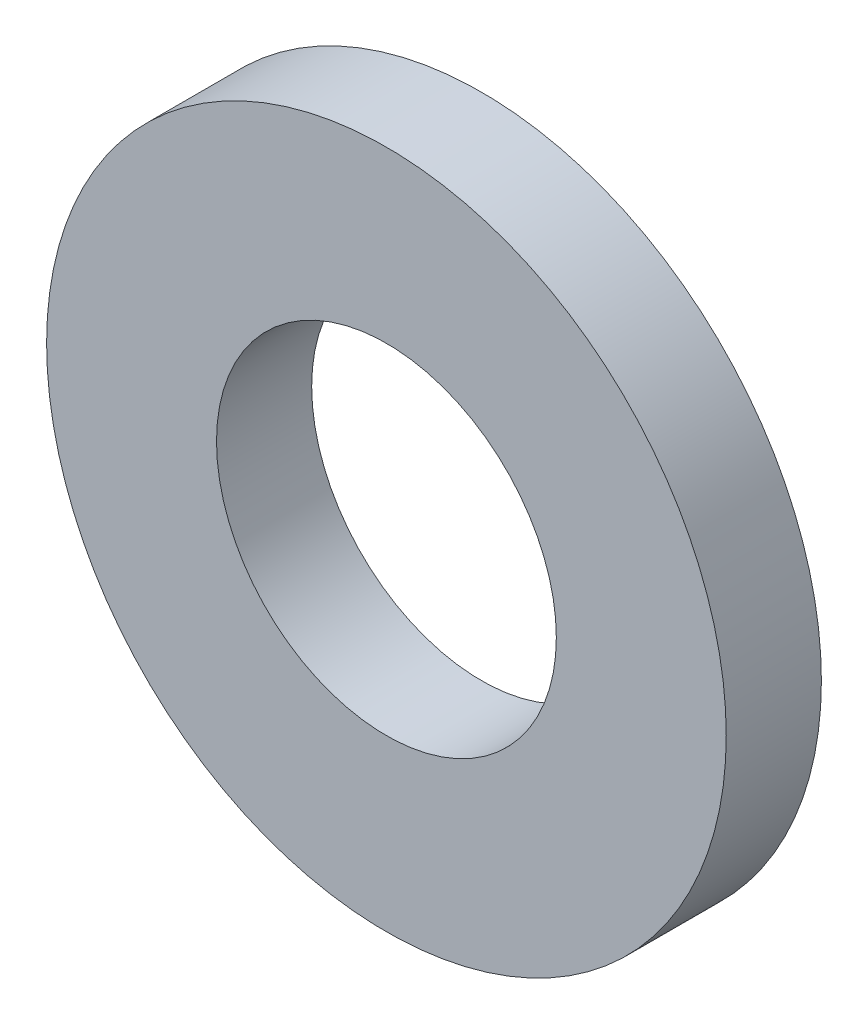
from build123d import *

# Parameters (mm, degrees)
SKETCH1_R           = 10
SKETCH1_R_2         = 5
BOSS_EXTRUDE1_DEPTH = 2.8


with BuildPart() as part:
    # Sketch1 → Boss-Extrude1 (new body)
    with BuildSketch(Plane.XY):
        Circle(SKETCH1_R)
        Circle(SKETCH1_R_2, mode=Mode.SUBTRACT)
    extrude(amount=BOSS_EXTRUDE1_DEPTH)


solid = part.part
